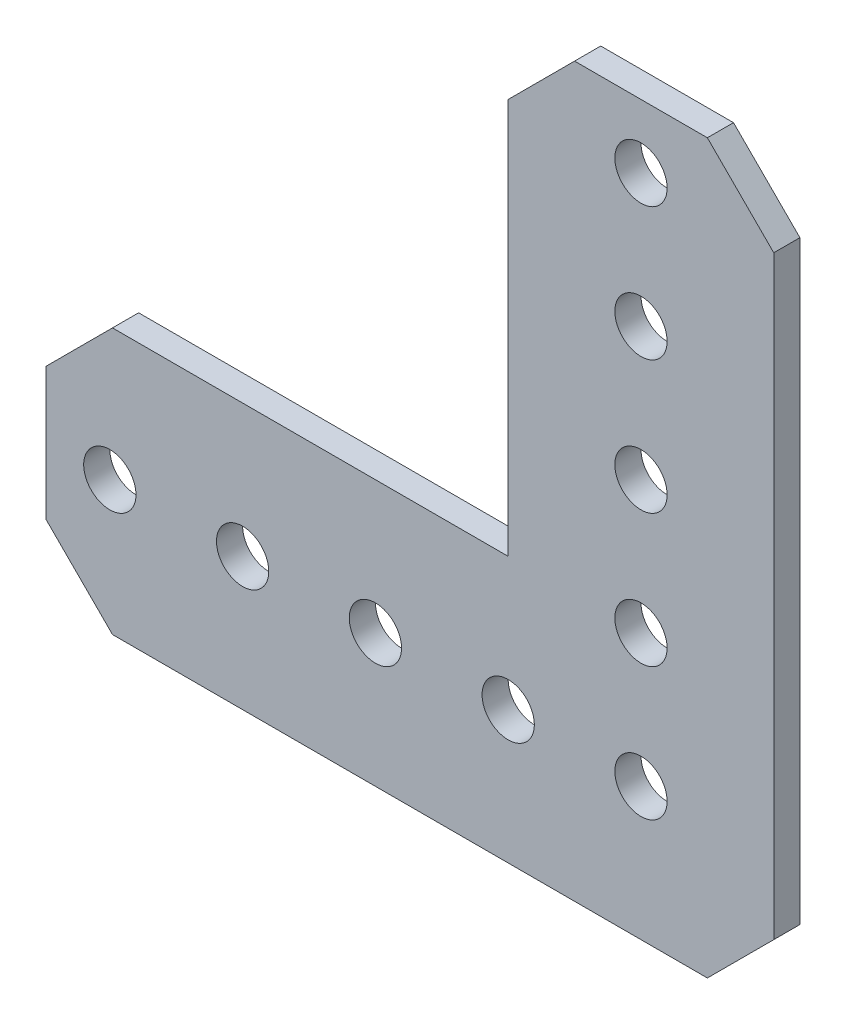
from build123d import *

# Parameters (mm, degrees)
SKETCH1_R           = 2.5
BOSS_EXTRUDE1_DEPTH = 2.5


with BuildPart() as part:
    # Sketch1 → Boss-Extrude1 (new body)
    with BuildSketch(Plane(origin=(0, 0, -1.25), x_dir=(-1, 0, 0), z_dir=(0, 0, -1))):
        Polygon((-6.35, -12.7), (50.546, -12.7), (56.896, -6.35), (56.896, 6.35), (50.546, 12.7), (12.7, 12.7), (12.7, 50.546), (6.35, 56.896), (-6.35, 56.896), (-12.7, 50.546), (-12.7, -6.35), align=None)
        with Locations((0, 12.7)):
            Circle(SKETCH1_R, mode=Mode.SUBTRACT)
        with Locations((0, 25.4)):
            Circle(SKETCH1_R, mode=Mode.SUBTRACT)
        with Locations((12.7, 0)):
            Circle(SKETCH1_R, mode=Mode.SUBTRACT)
        with Locations((25.4, 0)):
            Circle(SKETCH1_R, mode=Mode.SUBTRACT)
        Circle(SKETCH1_R, mode=Mode.SUBTRACT)
        with Locations((50.8, 0)):
            Circle(SKETCH1_R, mode=Mode.SUBTRACT)
        with Locations((38.1, 0)):
            Circle(SKETCH1_R, mode=Mode.SUBTRACT)
        with Locations((0, 50.8)):
            Circle(SKETCH1_R, mode=Mode.SUBTRACT)
        with Locations((0, 38.1)):
            Circle(SKETCH1_R, mode=Mode.SUBTRACT)
    extrude(amount=-BOSS_EXTRUDE1_DEPTH)


solid = part.part
